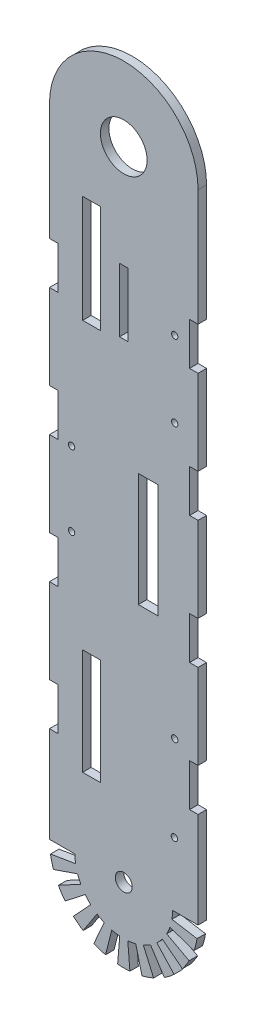
from build123d import *

# Parameters (mm, degrees)
SKETCH1_R           = 4
SKETCH1_R_2         = 11
SKETCH1_R_3         = 1.5
SKETCH1_W           = 4
SKETCH1_H           = 30
SKETCH1_W_2         = 8.515362535
SKETCH1_H_2         = 50.591793773
SKETCH1_W_3         = 9.363802293
SKETCH1_H_3         = 53.507441676
SKETCH1_H_4         = 49.971994441
BOSS_EXTRUDE1_DEPTH = 4


with BuildPart() as part:
    # Sketch1 → Boss-Extrude1 (new body)
    with BuildSketch(Plane.XY):
        with BuildLine():
            Line((-35, 300), (-35, 245.119310596))
            Line((-35, 245.119310596), (-31, 245.119310596))
            Line((-31, 245.119310596), (-31, 225.119310596))
            Line((-31, 225.119310596), (-35, 225.119310596))
            Line((-35, 225.119310596), (-35, 185.119310596))
            Line((-35, 185.119310596), (-31, 185.119310596))
            Line((-31, 185.119310596), (-31, 165.119310596))
            Line((-31, 165.119310596), (-35, 165.119310596))
            Line((-35, 165.119310596), (-35, 125.119310596))
            Line((-35, 125.119310596), (-31, 125.119310596))
            Line((-31, 125.119310596), (-31, 105.119310596))
            Line((-31, 105.119310596), (-35, 105.119310596))
            Line((-35, 105.119310596), (-35, 65.119310596))
            Line((-35, 65.119310596), (-31, 65.119310596))
            Line((-31, 65.119310596), (-31, 45.119310596))
            Line((-31, 45.119310596), (-35, 45.119310596))
            Line((-35, 45.119310596), (-35, 0))
            Line((-35, 0), (-23, 0))
            ThreePointArc((-23, 0), (-22.921443339, -1.899324946), (-22.686309978, -3.785675576))
            Line((-22.686309978, -3.785675576), (-34.522645619, -5.76081066))
            ThreePointArc((-34.522645619, -5.76081066), (-33.929009308, -8.59199205), (-33.10360346, -11.364481422))
            Line((-33.10360346, -11.364481422), (-21.753796559, -7.468087792))
            ThreePointArc((-21.753796559, -7.468087792), (-21.062786513, -9.238994767), (-20.227896278, -10.94679004))
            Line((-20.227896278, -10.94679004), (-30.781581292, -16.658158756))
            ThreePointArc((-30.781581292, -16.658158756), (-29.300826739, -19.143185534), (-27.619917829, -21.497444944))
            Line((-27.619917829, -21.497444944), (-18.150231716, -14.126892392))
            ThreePointArc((-18.150231716, -14.126892392), (-16.921649945, -15.577476147), (-15.577476147, -16.921649945))
            Line((-15.577476147, -16.921649945), (-23.704855007, -25.750336874))
            ThreePointArc((-23.704855007, -25.750336874), (-21.497444944, -27.619917829), (-19.143185534, -29.300826739))
            Line((-19.143185534, -29.300826739), (-12.579807637, -19.254829))
            ThreePointArc((-12.579807637, -19.254829), (-10.94679004, -20.227896278), (-9.238994767, -21.062786513))
            Line((-9.238994767, -21.062786513), (-14.059339863, -32.052066433))
            ThreePointArc((-14.059339863, -32.052066433), (-11.364481422, -33.10360346), (-8.59199205, -33.929009308))
            Line((-8.59199205, -33.929009308), (-5.646166204, -22.296206117))
            ThreePointArc((-5.646166204, -22.296206117), (-3.785675576, -22.686309978), (-1.899324946, -22.921443339))
            Line((-1.899324946, -22.921443339), (-2.890277092, -34.880457255))
            ThreePointArc((-2.890277092, -34.880457255), (0, -35), (2.890277092, -34.880457255))
            Line((2.890277092, -34.880457255), (1.899324946, -22.921443339))
            ThreePointArc((1.899324946, -22.921443339), (3.785675576, -22.686309978), (5.646166204, -22.296206117))
            Line((5.646166204, -22.296206117), (8.59199205, -33.929009308))
            ThreePointArc((8.59199205, -33.929009308), (11.364481422, -33.10360346), (14.059339863, -32.052066433))
            Line((14.059339863, -32.052066433), (9.238994767, -21.062786513))
            ThreePointArc((9.238994767, -21.062786513), (10.94679004, -20.227896278), (12.579807637, -19.254829))
            Line((12.579807637, -19.254829), (19.143185534, -29.300826739))
            ThreePointArc((19.143185534, -29.300826739), (21.497444944, -27.619917829), (23.704855007, -25.750336874))
            Line((23.704855007, -25.750336874), (15.577476147, -16.921649945))
            ThreePointArc((15.577476147, -16.921649945), (16.921649945, -15.577476147), (18.150231716, -14.126892392))
            Line((18.150231716, -14.126892392), (27.619917829, -21.497444944))
            ThreePointArc((27.619917829, -21.497444944), (29.300826739, -19.143185534), (30.781581292, -16.658158756))
            Line((30.781581292, -16.658158756), (20.227896278, -10.94679004))
            ThreePointArc((20.227896278, -10.94679004), (21.062786513, -9.238994767), (21.753796559, -7.468087792))
            Line((21.753796559, -7.468087792), (33.10360346, -11.364481422))
            ThreePointArc((33.10360346, -11.364481422), (33.929009308, -8.59199205), (34.522645619, -5.76081066))
            Line((34.522645619, -5.76081066), (22.686309978, -3.785675576))
            ThreePointArc((22.686309978, -3.785675576), (22.921443339, -1.899324946), (23, 0))
            Line((23, 0), (35, 0))
            Line((35, 0), (35, 45.119310596))
            Line((35, 45.119310596), (31, 45.119310596))
            Line((31, 45.119310596), (31, 65.119310596))
            Line((31, 65.119310596), (35, 65.119310596))
            Line((35, 65.119310596), (35, 105.119310596))
            Line((35, 105.119310596), (31, 105.119310596))
            Line((31, 105.119310596), (31, 125.119310596))
            Line((31, 125.119310596), (35, 125.119310596))
            Line((35, 125.119310596), (35, 165.119310596))
            Line((35, 165.119310596), (31, 165.119310596))
            Line((31, 165.119310596), (31, 185.119310596))
            Line((31, 185.119310596), (35, 185.119310596))
            Line((35, 185.119310596), (35, 225.119310596))
            Line((35, 225.119310596), (31, 225.119310596))
            Line((31, 225.119310596), (31, 245.119310596))
            Line((31, 245.119310596), (35, 245.119310596))
            Line((35, 245.119310596), (35, 300))
            ThreePointArc((35, 300), (0, 335), (-35, 300))
        make_face()
        Circle(SKETCH1_R, mode=Mode.SUBTRACT)
        with Locations((0, 300)):
            Circle(SKETCH1_R_2, mode=Mode.SUBTRACT)
        with Locations((23.996702537, 235.091311609)):
            Circle(SKETCH1_R_3, mode=Mode.SUBTRACT)
        with Locations((-24.57592592, 165.712200906)):
            Circle(SKETCH1_R_3, mode=Mode.SUBTRACT)
        with Locations((23.996702545, 199.384614522)):
            Circle(SKETCH1_R_3, mode=Mode.SUBTRACT)
        with Locations((-24.57592592, 130.741920595)):
            Circle(SKETCH1_R_3, mode=Mode.SUBTRACT)
        with Locations((23.996702545, 70.517408204)):
            Circle(SKETCH1_R_3, mode=Mode.SUBTRACT)
        with Locations((23.834109516, 30.143932105)):
            Circle(SKETCH1_R_3, mode=Mode.SUBTRACT)
        with Locations((0, 236.5)):
            Rectangle(SKETCH1_W, SKETCH1_H, mode=Mode.SUBTRACT)
        with Locations((-15.100973899, 244.828514205)):
            Rectangle(SKETCH1_W_2, SKETCH1_H_2, mode=Mode.SUBTRACT)
        with Locations((11.541273102, 143.451426266)):
            Rectangle(SKETCH1_W_3, SKETCH1_H_3, mode=Mode.SUBTRACT)
        with Locations((-15.100973899, 60.133313376)):
            Rectangle(SKETCH1_W_2, SKETCH1_H_4, mode=Mode.SUBTRACT)
    extrude(amount=BOSS_EXTRUDE1_DEPTH)


solid = part.part
